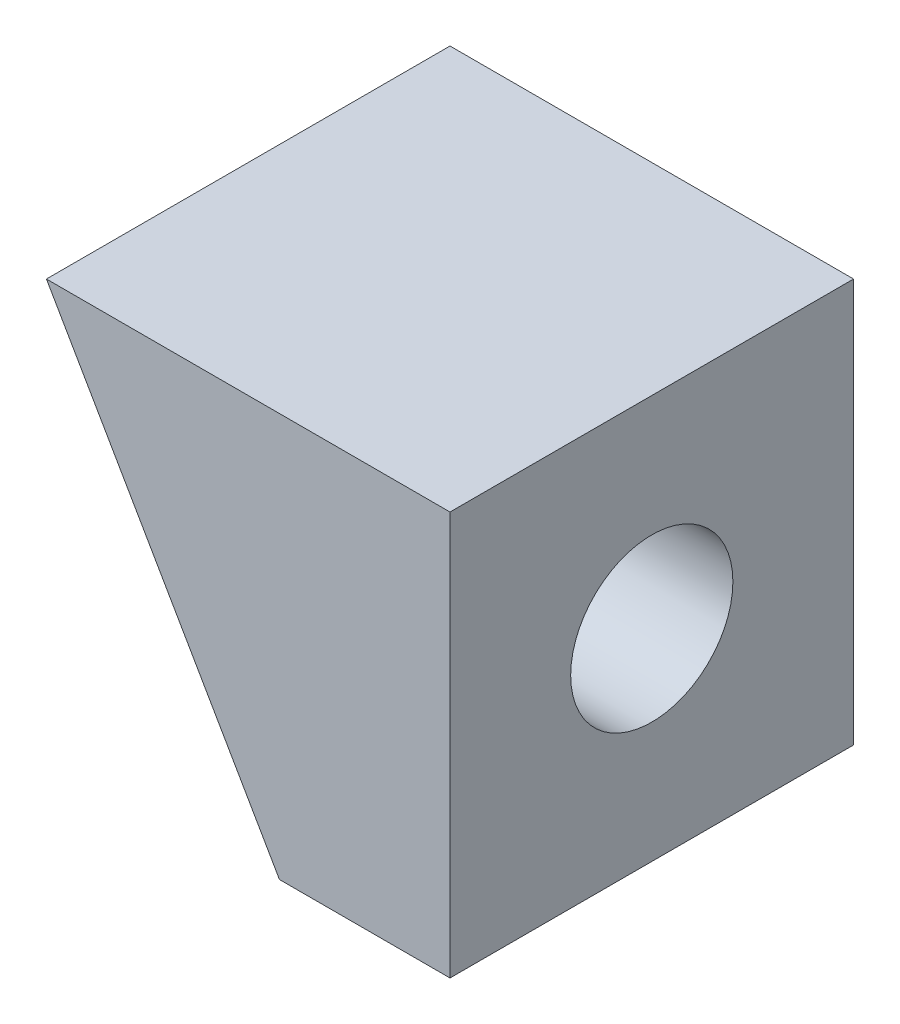
from build123d import *

# Parameters (mm, degrees)
SKETCH1_W              = 12.7
SKETCH1_H              = 12.7
BOSS_EXTRUDE1_DEPTH    = 12.7
CUT_EXTRUDE1_DEPTH     = 13.7
F_10_CLEARANCE_HOLE1_D = 5.1054


with BuildPart() as part:
    # Sketch1 → Boss-Extrude1 (new body)
    with BuildSketch(Plane(origin=(0, 0, 0), x_dir=(0, 0, -1), z_dir=(1, 0, 0))):
        with Locations((6.35, 6.35)):
            Rectangle(SKETCH1_W, SKETCH1_H)
    extrude(amount=BOSS_EXTRUDE1_DEPTH)

    # Sketch2 → Cut-Extrude1 (cut, through all)
    with BuildSketch(Plane.XY):
        Polygon((7.332348419, 0), (0, 12.7), (0, 0), align=None)
    extrude(amount=-CUT_EXTRUDE1_DEPTH, mode=Mode.SUBTRACT)

    # #10 Clearance Hole1 (through all)
    with Locations(Plane(origin=(12.7, 6.35, -6.35), x_dir=(0, 0, 1), z_dir=(1, 0, 0))):
        with Locations((0, 0)):
            Hole(F_10_CLEARANCE_HOLE1_D / 2)


solid = part.part
